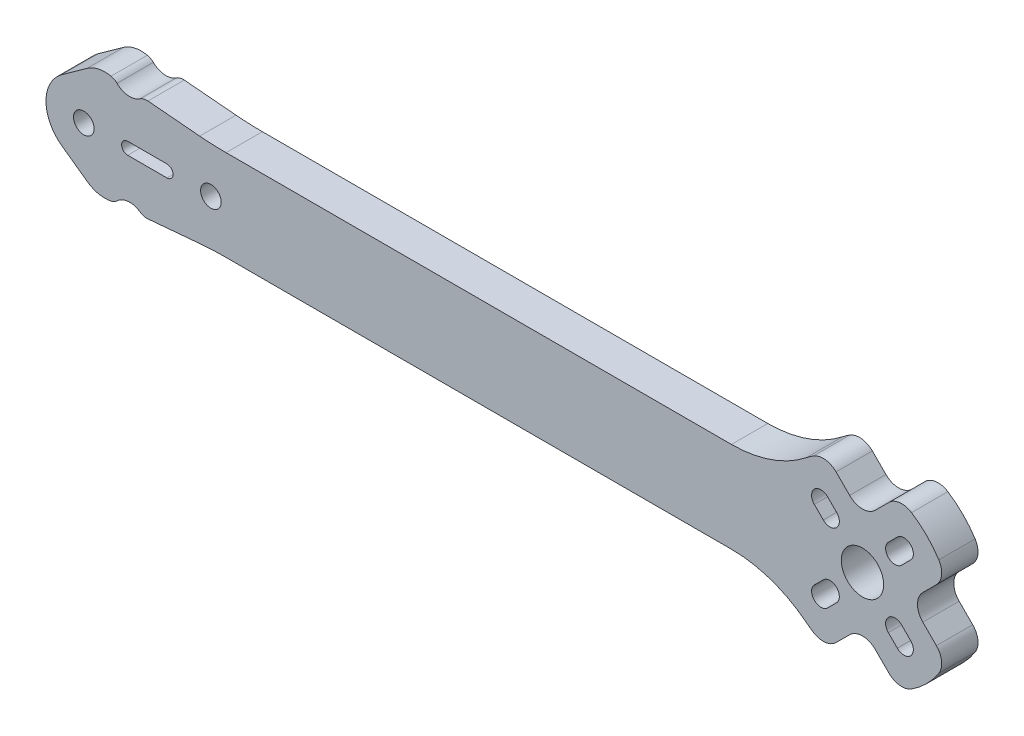
from build123d import *

# Parameters (mm, degrees)
SKETCH1_R                = 3.5
BOSS_EXTRUDE1_DEPTH      = 6
M3_CLEARANCE_HOLE1_D     = 3.4
M3_CLEARANCE_HOLE1_DEPTH = 6


with BuildPart() as part:
    # Sketch1 → Boss-Extrude1 (new body)
    with BuildSketch(Plane.XY):
        with BuildLine():
            Line((-118.078026422, -8.43859944), (-109.524525727, -7.690265095))
            ThreePointArc((-109.524525727, -7.690265095), (-107.347707958, -7.547588921), (-105.16673859, -7.5))
            Line((-105.16673859, -7.5), (-21.650635095, -7.5))
            ThreePointArc((-21.650635095, -7.5), (-15.104098388, -8.60177635), (-9.278843612, -11.785714286))
            ThreePointArc((-9.278843612, -11.785714286), (-8.704608747, -12.215964414), (-8.110455382, -12.618261112))
            ThreePointArc((-8.110455382, -12.618261112), (-6.167778591, -13.077430507), (-4.367043962, -12.215929233))
            Line((-4.367043962, -12.215929233), (-2.121320344, -9.970205615))
            ThreePointArc((-2.121320344, -9.970205615), (0, -9.091525958), (2.121320344, -9.970205615))
            Line((2.121320344, -9.970205615), (4.367043962, -12.215929233))
            ThreePointArc((4.367043962, -12.215929233), (6.167778591, -13.077430507), (8.110455382, -12.618261112))
            ThreePointArc((8.110455382, -12.618261112), (10.606601718, -10.606601718), (12.618261112, -8.110455382))
            ThreePointArc((12.618261112, -8.110455382), (13.077430507, -6.167778591), (12.215929233, -4.367043962))
            Line((12.215929233, -4.367043962), (9.970205615, -2.121320344))
            ThreePointArc((9.970205615, -2.121320344), (9.091525958, 0), (9.970205615, 2.121320344))
            Line((9.970205615, 2.121320344), (12.215929233, 4.367043962))
            ThreePointArc((12.215929233, 4.367043962), (13.077430507, 6.167778591), (12.618261112, 8.110455382))
            ThreePointArc((12.618261112, 8.110455382), (10.606601718, 10.606601718), (8.110455382, 12.618261112))
            ThreePointArc((8.110455382, 12.618261112), (6.167778591, 13.077430507), (4.367043962, 12.215929233))
            Line((4.367043962, 12.215929233), (2.121320344, 9.970205615))
            ThreePointArc((2.121320344, 9.970205615), (0, 9.091525958), (-2.121320344, 9.970205615))
            Line((-2.121320344, 9.970205615), (-4.367043962, 12.215929233))
            ThreePointArc((-4.367043962, 12.215929233), (-6.167778591, 13.077430507), (-8.110455382, 12.618261112))
            ThreePointArc((-8.110455382, 12.618261112), (-8.704608747, 12.215964414), (-9.278843612, 11.785714286))
            ThreePointArc((-9.278843612, 11.785714286), (-15.104098388, 8.60177635), (-21.650635095, 7.5))
            Line((-21.650635095, 7.5), (-105.16673859, 7.5))
            ThreePointArc((-105.16673859, 7.5), (-107.347707958, 7.547588921), (-109.524525727, 7.690265095))
            Line((-109.524525727, 7.690265095), (-118.078026422, 8.43859944))
            ThreePointArc((-118.078026422, 8.43859944), (-118.763989135, 8.379655937), (-119.389318724, 8.091589824))
            ThreePointArc((-119.389318724, 8.091589824), (-121.346764731, 7.570260106), (-123.189327607, 8.411890421))
            ThreePointArc((-123.189327607, 8.411890421), (-123.647802273, 8.746502417), (-124.181815085, 8.938842024))
            ThreePointArc((-124.181815085, 8.938842024), (-126.232348099, 8.932309996), (-128.107820511, 8.103255389))
            Line((-128.107820511, 8.103255389), (-132.322652835, 5.076759373))
            ThreePointArc((-132.322652835, 5.076759373), (-134.927242807, 0), (-132.322652835, -5.076759373))
            Line((-132.322652835, -5.076759373), (-128.107820511, -8.103255389))
            ThreePointArc((-128.107820511, -8.103255389), (-126.232348099, -8.932309996), (-124.181815085, -8.938842024))
            ThreePointArc((-124.181815085, -8.938842024), (-123.647802273, -8.746502417), (-123.189327607, -8.411890421))
            ThreePointArc((-123.189327607, -8.411890421), (-121.346764731, -7.570260106), (-119.389318724, -8.091589824))
            ThreePointArc((-119.389318724, -8.091589824), (-118.763989135, -8.379655937), (-118.078026422, -8.43859944))
        make_face()
        Circle(SKETCH1_R, mode=Mode.SUBTRACT)
        with BuildLine():
            Line((7.954951288, 5.762920267), (6.470027048, 4.277996026))
            ThreePointArc((6.470027048, 4.277996026), (4.277996026, 4.277996026), (4.277996026, 6.470027048))
            Line((4.277996026, 6.470027048), (5.762920267, 7.954951288))
            ThreePointArc((5.762920267, 7.954951288), (7.954951288, 7.954951288), (7.954951288, 5.762920267))
        make_face(mode=Mode.SUBTRACT)
        with BuildLine():
            Line((-5.762920267, 7.954951288), (-4.277996026, 6.470027048))
            ThreePointArc((-4.277996026, 6.470027048), (-4.277996026, 4.277996026), (-6.470027048, 4.277996026))
            Line((-6.470027048, 4.277996026), (-7.954951288, 5.762920267))
            ThreePointArc((-7.954951288, 5.762920267), (-7.954951288, 7.954951288), (-5.762920267, 7.954951288))
        make_face(mode=Mode.SUBTRACT)
        with BuildLine():
            Line((5.762920267, -7.954951288), (4.277996026, -6.470027048))
            ThreePointArc((4.277996026, -6.470027048), (4.277996026, -4.277996026), (6.470027048, -4.277996026))
            Line((6.470027048, -4.277996026), (7.954951288, -5.762920267))
            ThreePointArc((7.954951288, -5.762920267), (7.954951288, -7.954951288), (5.762920267, -7.954951288))
        make_face(mode=Mode.SUBTRACT)
        with BuildLine():
            Line((-7.954951288, -5.762920267), (-6.470027048, -4.277996026))
            ThreePointArc((-6.470027048, -4.277996026), (-4.277996026, -4.277996026), (-4.277996026, -6.470027048))
            Line((-4.277996026, -6.470027048), (-5.762920267, -7.954951288))
            ThreePointArc((-5.762920267, -7.954951288), (-7.954951288, -7.954951288), (-7.954951288, -5.762920267))
        make_face(mode=Mode.SUBTRACT)
        with BuildLine():
            Line((-121.427242807, 1), (-114.927242807, 1))
            ThreePointArc((-114.927242807, 1), (-113.927242807, 0), (-114.927242807, -1))
            Line((-114.927242807, -1), (-121.427242807, -1))
            ThreePointArc((-121.427242807, -1), (-122.427242807, 0), (-121.427242807, 1))
        make_face(mode=Mode.SUBTRACT)
    extrude(amount=BOSS_EXTRUDE1_DEPTH)

    # M3 Clearance Hole1
    with Locations(Plane.XY.offset(6)):
        with Locations((-107.677242807, 0), (-128.677242807, 0)):
            Hole(M3_CLEARANCE_HOLE1_D / 2, depth=M3_CLEARANCE_HOLE1_DEPTH)


solid = part.part
